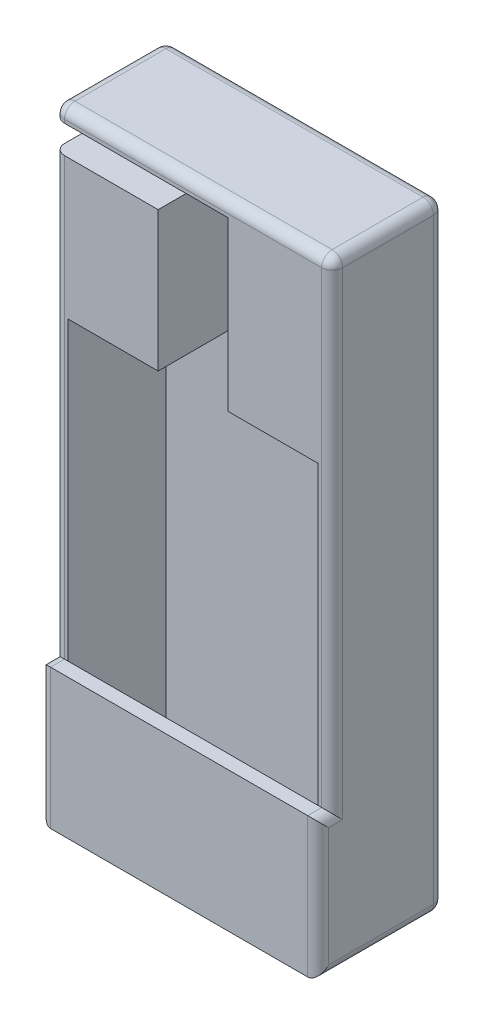
from build123d import *

# Parameters (mm, degrees)
SKETCH1_W            = 2.54
SKETCH1_H            = 2.54
BOSS_EXTRUDE3_DEPTH  = 5.588
BOSS_EXTRUDE4_START  = 5.588
BOSS_EXTRUDE4_DEPTH  = 73.66
BOSS_EXTRUDE6_START  = 79.248
SKETCH1_8_W          = 2.54
SKETCH1_8_H          = 2.54
SKETCH1_8_W_2        = 13.843
BOSS_EXTRUDE6_DEPTH  = 30.48
BOSS_EXTRUDE7_START  = 109.728
SKETCH1_9_W          = 12.7
SKETCH1_9_H          = 2.54
SKETCH1_9_W_2        = 2.54
SKETCH1_9_W_3        = 13.843
BOSS_EXTRUDE7_DEPTH  = 2.54
SKETCH4_W            = 50.546
SKETCH4_H            = 25.4
BOSS_EXTRUDE10_DEPTH = 2.54
FILLET1_R            = 1.905
SKETCH3_W            = 20.193
SKETCH3_H            = 5.08
CUT_EXTRUDE3_DEPTH   = 17.78


with BuildPart() as part:
    # Sketch1 → Boss-Extrude3 (new body)
    with BuildSketch(Plane(origin=(0, 0, 0), x_dir=(1, 0, 0), z_dir=(0, 1, 0))):
        with BuildLine():
            Line((-22.733, -10.16), (-22.733, -7.62))
            Line((-22.733, -7.62), (-22.733, 7.62))
            Line((-22.733, 7.62), (-5.08, 7.62))
            ThreePointArc((-5.08, 7.62), (-2.839806331, 9.489612663), (0, 10.16))
            Line((0, 10.16), (-25.273, 10.16))
            Line((-25.273, 10.16), (-25.273, -10.16))
            Line((-25.273, -10.16), (-22.733, -10.16))
        make_face()
        with BuildLine():
            ThreePointArc((0, 10.16), (2.839806331, 9.489612663), (5.08, 7.62))
            Line((5.08, 7.62), (22.733, 7.62))
            Line((22.733, 7.62), (22.733, -7.62))
            Line((22.733, -7.62), (22.733, -10.16))
            Line((22.733, -10.16), (25.273, -10.16))
            Line((25.273, -10.16), (25.273, 10.16))
            Line((25.273, 10.16), (0, 10.16))
        make_face()
        with BuildLine():
            ThreePointArc((0, 10.16), (-2.839806331, 9.489612663), (-5.08, 7.62))
            Line((-5.08, 7.62), (5.08, 7.62))
            ThreePointArc((5.08, 7.62), (2.839806331, 9.489612663), (0, 10.16))
        make_face()
        with BuildLine():
            Line((-22.733, 7.62), (-22.733, -7.62))
            Line((-22.733, -7.62), (-20.193, -7.62))
            Line((-20.193, -7.62), (-20.193, -5.08))
            Line((-20.193, -5.08), (-20.193, 5.08))
            Line((-20.193, 5.08), (-6.221703947, 5.08))
            ThreePointArc((-6.221703947, 5.08), (-5.791806974, 6.413357827), (-5.08, 7.62))
            Line((-5.08, 7.62), (-22.733, 7.62))
        make_face()
        with Locations((-21.463, -8.89)):
            Rectangle(SKETCH1_W, SKETCH1_H)
        with BuildLine():
            Line((5.08, 7.62), (-5.08, 7.62))
            ThreePointArc((-5.08, 7.62), (-5.791806974, 6.413357827), (-6.221703947, 5.08))
            Line((-6.221703947, 5.08), (6.221703947, 5.08))
            ThreePointArc((6.221703947, 5.08), (5.791806974, 6.413357827), (5.08, 7.62))
        make_face()
        with BuildLine():
            Line((22.733, 7.62), (5.08, 7.62))
            ThreePointArc((5.08, 7.62), (5.791806974, 6.413357827), (6.221703947, 5.08))
            Line((6.221703947, 5.08), (20.193, 5.08))
            Line((20.193, 5.08), (20.193, -5.08))
            Line((20.193, -5.08), (20.193, -7.62))
            Line((20.193, -7.62), (22.733, -7.62))
            Line((22.733, -7.62), (22.733, 7.62))
        make_face()
        with Locations((21.463, -8.89)):
            Rectangle(SKETCH1_W, SKETCH1_H)
    extrude(amount=BOSS_EXTRUDE3_DEPTH)

    # Sketch1_7 → Boss-Extrude4 (add)
    with BuildSketch(Plane(origin=(0, 0, 0), x_dir=(1, 0, 0), z_dir=(0, 1, 0)).offset(BOSS_EXTRUDE4_START)):
        with BuildLine():
            Line((-22.733, -10.16), (-22.733, -7.62))
            Line((-22.733, -7.62), (-22.733, 7.62))
            Line((-22.733, 7.62), (-5.08, 7.62))
            ThreePointArc((-5.08, 7.62), (-2.839806331, 9.489612663), (0, 10.16))
            Line((0, 10.16), (-25.273, 10.16))
            Line((-25.273, 10.16), (-25.273, -10.16))
            Line((-25.273, -10.16), (-22.733, -10.16))
        make_face()
        with BuildLine():
            ThreePointArc((0, 10.16), (2.839806331, 9.489612663), (5.08, 7.62))
            Line((5.08, 7.62), (22.733, 7.62))
            Line((22.733, 7.62), (22.733, -7.62))
            Line((22.733, -7.62), (22.733, -10.16))
            Line((22.733, -10.16), (25.273, -10.16))
            Line((25.273, -10.16), (25.273, 10.16))
            Line((25.273, 10.16), (0, 10.16))
        make_face()
        with BuildLine():
            ThreePointArc((0, 10.16), (-2.839806331, 9.489612663), (-5.08, 7.62))
            Line((-5.08, 7.62), (5.08, 7.62))
            ThreePointArc((5.08, 7.62), (2.839806331, 9.489612663), (0, 10.16))
        make_face()
    extrude(amount=BOSS_EXTRUDE4_DEPTH)

    # Sketch1_8 → Boss-Extrude6 (add)
    with BuildSketch(Plane(origin=(0, 0, 0), x_dir=(1, 0, 0), z_dir=(0, 1, 0)).offset(BOSS_EXTRUDE6_START)):
        with BuildLine():
            Line((-22.733, -10.16), (-22.733, -7.62))
            Line((-22.733, -7.62), (-22.733, 7.62))
            Line((-22.733, 7.62), (-5.08, 7.62))
            ThreePointArc((-5.08, 7.62), (-2.839806331, 9.489612663), (0, 10.16))
            Line((0, 10.16), (-25.273, 10.16))
            Line((-25.273, 10.16), (-25.273, -10.16))
            Line((-25.273, -10.16), (-22.733, -10.16))
        make_face()
        with BuildLine():
            Line((-22.733, 7.62), (-22.733, -7.62))
            Line((-22.733, -7.62), (-20.193, -7.62))
            Line((-20.193, -7.62), (-20.193, -5.08))
            Line((-20.193, -5.08), (-20.193, 5.08))
            Line((-20.193, 5.08), (-6.221703947, 5.08))
            ThreePointArc((-6.221703947, 5.08), (-5.791806974, 6.413357827), (-5.08, 7.62))
            Line((-5.08, 7.62), (-22.733, 7.62))
        make_face()
        with BuildLine():
            Line((-20.193, -5.08), (-20.193, -7.62))
            Line((-20.193, -7.62), (-6.35, -7.62))
            Line((-6.35, -7.62), (-6.35, -3.175))
            Line((-6.35, -3.175), (-6.35, 3.81))
            ThreePointArc((-6.35, 3.81), (-6.317844572, 4.448231909), (-6.221703947, 5.08))
            Line((-6.221703947, 5.08), (-20.193, 5.08))
            Line((-20.193, 5.08), (-20.193, -5.08))
        make_face()
        with Locations((-21.463, -8.89)):
            Rectangle(SKETCH1_8_W, SKETCH1_8_H)
        with Locations((-13.2715, -8.89)):
            Rectangle(SKETCH1_8_W_2, SKETCH1_8_H)
        with BuildLine():
            ThreePointArc((0, 10.16), (2.839806331, 9.489612663), (5.08, 7.62))
            Line((5.08, 7.62), (22.733, 7.62))
            Line((22.733, 7.62), (22.733, -7.62))
            Line((22.733, -7.62), (22.733, -10.16))
            Line((22.733, -10.16), (25.273, -10.16))
            Line((25.273, -10.16), (25.273, 10.16))
            Line((25.273, 10.16), (0, 10.16))
        make_face()
        with BuildLine():
            Line((22.733, 7.62), (5.08, 7.62))
            ThreePointArc((5.08, 7.62), (5.791806974, 6.413357827), (6.221703947, 5.08))
            Line((6.221703947, 5.08), (20.193, 5.08))
            Line((20.193, 5.08), (20.193, -5.08))
            Line((20.193, -5.08), (20.193, -7.62))
            Line((20.193, -7.62), (22.733, -7.62))
            Line((22.733, -7.62), (22.733, 7.62))
        make_face()
        with BuildLine():
            Line((6.35, -3.175), (6.35, -7.62))
            Line((6.35, -7.62), (20.193, -7.62))
            Line((20.193, -7.62), (20.193, -5.08))
            Line((20.193, -5.08), (20.193, 5.08))
            Line((20.193, 5.08), (6.221703947, 5.08))
            ThreePointArc((6.221703947, 5.08), (6.317844572, 4.448231909), (6.35, 3.81))
            Line((6.35, 3.81), (6.35, -3.175))
        make_face()
        with Locations((13.2715, -8.89)):
            Rectangle(SKETCH1_8_W_2, SKETCH1_8_H)
        with Locations((21.463, -8.89)):
            Rectangle(SKETCH1_8_W, SKETCH1_8_H)
        with BuildLine():
            ThreePointArc((0, 10.16), (-2.839806331, 9.489612663), (-5.08, 7.62))
            Line((-5.08, 7.62), (5.08, 7.62))
            ThreePointArc((5.08, 7.62), (2.839806331, 9.489612663), (0, 10.16))
        make_face()
    extrude(amount=BOSS_EXTRUDE6_DEPTH)

    # Sketch1_9 → Boss-Extrude7 (add)
    with BuildSketch(Plane(origin=(0, 0, 0), x_dir=(1, 0, 0), z_dir=(0, 1, 0)).offset(BOSS_EXTRUDE7_START)):
        with BuildLine():
            Line((-6.35, -3.175), (-6.35, -7.62))
            Line((-6.35, -7.62), (6.35, -7.62))
            Line((6.35, -7.62), (6.35, -3.175))
            Line((6.35, -3.175), (6.35, 3.81))
            ThreePointArc((6.35, 3.81), (6.317844572, 4.448231909), (6.221703947, 5.08))
            Line((6.221703947, 5.08), (-6.221703947, 5.08))
            ThreePointArc((-6.221703947, 5.08), (-6.317844572, 4.448231909), (-6.35, 3.81))
            Line((-6.35, 3.81), (-6.35, -3.175))
        make_face()
        with Locations((0, -8.89)):
            Rectangle(SKETCH1_9_W, SKETCH1_9_H)
        with BuildLine():
            Line((5.08, 7.62), (-5.08, 7.62))
            ThreePointArc((-5.08, 7.62), (-5.791806974, 6.413357827), (-6.221703947, 5.08))
            Line((-6.221703947, 5.08), (6.221703947, 5.08))
            ThreePointArc((6.221703947, 5.08), (5.791806974, 6.413357827), (5.08, 7.62))
        make_face()
        with BuildLine():
            Line((-22.733, -10.16), (-22.733, -7.62))
            Line((-22.733, -7.62), (-22.733, 7.62))
            Line((-22.733, 7.62), (-5.08, 7.62))
            ThreePointArc((-5.08, 7.62), (-2.839806331, 9.489612663), (0, 10.16))
            Line((0, 10.16), (-25.273, 10.16))
            Line((-25.273, 10.16), (-25.273, -10.16))
            Line((-25.273, -10.16), (-22.733, -10.16))
        make_face()
        with Locations((-21.463, -8.89)):
            Rectangle(SKETCH1_9_W_2, SKETCH1_9_H)
        with BuildLine():
            Line((-22.733, 7.62), (-22.733, -7.62))
            Line((-22.733, -7.62), (-20.193, -7.62))
            Line((-20.193, -7.62), (-20.193, -5.08))
            Line((-20.193, -5.08), (-20.193, 5.08))
            Line((-20.193, 5.08), (-6.221703947, 5.08))
            ThreePointArc((-6.221703947, 5.08), (-5.791806974, 6.413357827), (-5.08, 7.62))
            Line((-5.08, 7.62), (-22.733, 7.62))
        make_face()
        with Locations((-13.2715, -8.89)):
            Rectangle(SKETCH1_9_W_3, SKETCH1_9_H)
        with BuildLine():
            Line((-20.193, -5.08), (-20.193, -7.62))
            Line((-20.193, -7.62), (-6.35, -7.62))
            Line((-6.35, -7.62), (-6.35, -3.175))
            Line((-6.35, -3.175), (-6.35, 3.81))
            ThreePointArc((-6.35, 3.81), (-6.317844572, 4.448231909), (-6.221703947, 5.08))
            Line((-6.221703947, 5.08), (-20.193, 5.08))
            Line((-20.193, 5.08), (-20.193, -5.08))
        make_face()
        with BuildLine():
            ThreePointArc((0, 10.16), (-2.839806331, 9.489612663), (-5.08, 7.62))
            Line((-5.08, 7.62), (5.08, 7.62))
            ThreePointArc((5.08, 7.62), (2.839806331, 9.489612663), (0, 10.16))
        make_face()
        with BuildLine():
            Line((22.733, 7.62), (5.08, 7.62))
            ThreePointArc((5.08, 7.62), (5.791806974, 6.413357827), (6.221703947, 5.08))
            Line((6.221703947, 5.08), (20.193, 5.08))
            Line((20.193, 5.08), (20.193, -5.08))
            Line((20.193, -5.08), (20.193, -7.62))
            Line((20.193, -7.62), (22.733, -7.62))
            Line((22.733, -7.62), (22.733, 7.62))
        make_face()
        with BuildLine():
            ThreePointArc((0, 10.16), (2.839806331, 9.489612663), (5.08, 7.62))
            Line((5.08, 7.62), (22.733, 7.62))
            Line((22.733, 7.62), (22.733, -7.62))
            Line((22.733, -7.62), (22.733, -10.16))
            Line((22.733, -10.16), (25.273, -10.16))
            Line((25.273, -10.16), (25.273, 10.16))
            Line((25.273, 10.16), (0, 10.16))
        make_face()
        with BuildLine():
            Line((6.35, -3.175), (6.35, -7.62))
            Line((6.35, -7.62), (20.193, -7.62))
            Line((20.193, -7.62), (20.193, -5.08))
            Line((20.193, -5.08), (20.193, 5.08))
            Line((20.193, 5.08), (6.221703947, 5.08))
            ThreePointArc((6.221703947, 5.08), (6.317844572, 4.448231909), (6.35, 3.81))
            Line((6.35, 3.81), (6.35, -3.175))
        make_face()
        with Locations((13.2715, -8.89)):
            Rectangle(SKETCH1_9_W_3, SKETCH1_9_H)
        with Locations((21.463, -8.89)):
            Rectangle(SKETCH1_9_W_2, SKETCH1_9_H)
    extrude(amount=BOSS_EXTRUDE7_DEPTH)

    # Sketch4 → Boss-Extrude10 (add)
    with BuildSketch(Plane.XY.offset(10.16)):
        with Locations((0, 12.7)):
            Rectangle(SKETCH4_W, SKETCH4_H)
    extrude(amount=BOSS_EXTRUDE10_DEPTH)

    # Fillet1
    fillet1_edges = [part.edges().sort_by_distance(p)[0] for p in [
        (-25.273, 25.4, 11.43),
        (25.273, 25.4, 11.43),
        (-25.273, 12.7, 12.7),
        (25.273, 12.7, 12.7),
        (-25.273, 0, 1.27),
        (0, 0, -10.16),
        (25.273, 0, 1.27),
        (-25.273, 68.834, 10.16),
        (-25.273, 56.134, -10.16),
        (25.273, 56.134, -10.16),
        (25.273, 68.834, 10.16),
        (0, 112.268, 10.16),
        (25.273, 112.268, 0),
        (-25.273, 112.268, 0),
        (0, 112.268, -10.16),
    ]]
    fillet(fillet1_edges, radius=FILLET1_R)

    # Sketch3 → Cut-Extrude3 (cut)
    with BuildSketch(Plane.XY.offset(10.16)):
        with Locations((-15.1765, 107.188)):
            Rectangle(SKETCH3_W, SKETCH3_H)
    extrude(amount=-CUT_EXTRUDE3_DEPTH, mode=Mode.SUBTRACT)


solid = part.part
